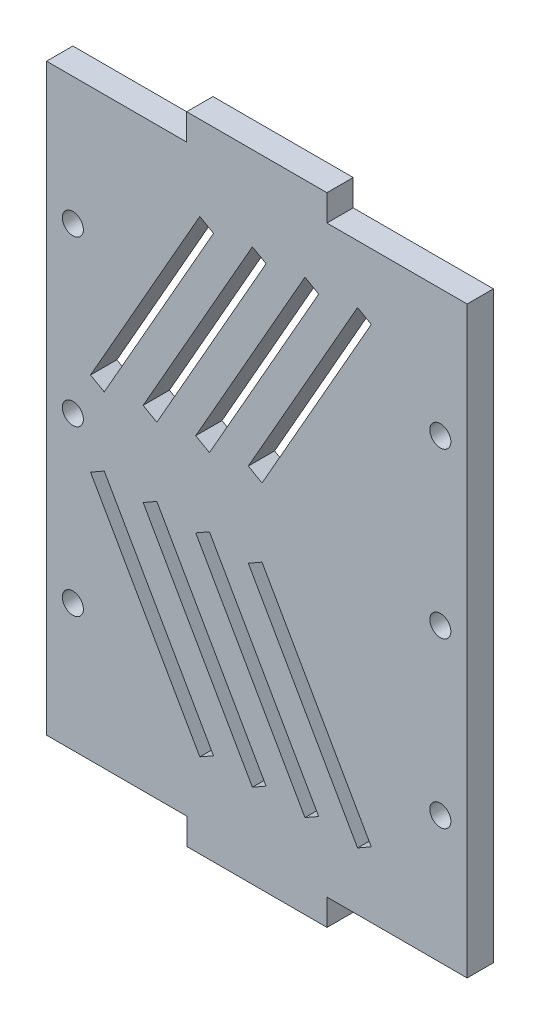
from build123d import *

# Parameters (mm, degrees)
CROQUIS1_W              = 79.981686337
CROQUIS1_H              = 111
SALIENTE_EXTRUIR1_DEPTH = 5
CROQUIS2_W              = 26.666666667
CROQUIS2_H              = 5
SALIENTE_EXTRUIR2_DEPTH = 5
CROQUIS3_W              = 26.666666666
CROQUIS3_H              = 5
SALIENTE_EXTRUIR3_DEPTH = 5
CROQUIS4_R              = 2
CORTAR_EXTRUIR1_DEPTH   = 10


with BuildPart() as part:
    # Croquis1 → Saliente-Extruir1 (new body)
    with BuildSketch(Plane.XY):
        with Locations((40.009156832, 55.428810295)):
            Rectangle(CROQUIS1_W, CROQUIS1_H)
        Polygon((40.989314194, 48.912995634), (38.382171337, 47.428810295), (59.160766092, 10.928810295), (61.767908949, 12.412995634), align=None, mode=Mode.SUBTRACT)
        Polygon((49.160766092, 10.928810295), (51.767908949, 12.412995634), (30.989314194, 48.912995634), (28.382171337, 47.428810295), align=None, mode=Mode.SUBTRACT)
        Polygon((20.989314194, 48.912995634), (18.382171337, 47.428810295), (39.160766092, 10.928810295), (41.767908949, 12.412995634), align=None, mode=Mode.SUBTRACT)
        Polygon((29.160766092, 10.928810295), (31.767908949, 12.412995634), (10.989314194, 48.912995634), (8.382171337, 47.428810295), align=None, mode=Mode.SUBTRACT)
        Polygon((38.382171337, 63.428810295), (40.989314194, 61.944624955), (61.767908949, 98.444624955), (59.160766092, 99.928810295), align=None, mode=Mode.SUBTRACT)
        Polygon((51.767908949, 98.444624955), (49.160766092, 99.928810295), (28.382171337, 63.428810295), (30.989314194, 61.944624955), align=None, mode=Mode.SUBTRACT)
        Polygon((18.382171337, 63.428810295), (20.989314194, 61.944624955), (41.767908949, 98.444624955), (39.160766092, 99.928810295), align=None, mode=Mode.SUBTRACT)
        Polygon((31.767908949, 98.444624955), (29.160766092, 99.928810295), (8.382171337, 63.428810295), (10.989314194, 61.944624955), align=None, mode=Mode.SUBTRACT)
    extrude(amount=SALIENTE_EXTRUIR1_DEPTH)

    # Croquis2 → Saliente-Extruir2 (add)
    with BuildSketch(Plane.XZ.offset(0.071189705)):
        with Locations((40.018313663, 2.5)):
            Rectangle(CROQUIS2_W, CROQUIS2_H)
    extrude(amount=SALIENTE_EXTRUIR2_DEPTH)

    # Croquis3 → Saliente-Extruir3 (add)
    with BuildSketch(Plane(origin=(0, 110.928810295, 0), x_dir=(1, 0, 0), z_dir=(0, 1, 0))):
        with Locations((40, -2.5)):
            Rectangle(CROQUIS3_W, CROQUIS3_H)
    extrude(amount=SALIENTE_EXTRUIR3_DEPTH)

    # Croquis4 → Cortar-Extruir1 (cut)
    with BuildSketch(Plane.XY.offset(5)):
        with Locations((74.9, 55.428810295)):
            Circle(CROQUIS4_R)
        with Locations((74.9, 86.678810295)):
            Circle(CROQUIS4_R)
        with Locations((74.9, 24.178810295)):
            Circle(CROQUIS4_R)
        with Locations((5.018313663, 55.428810295)):
            Circle(CROQUIS4_R)
        with Locations((5.018313663, 86.678810295)):
            Circle(CROQUIS4_R)
        with Locations((5.018313663, 24.178810295)):
            Circle(CROQUIS4_R)
    extrude(amount=-CORTAR_EXTRUIR1_DEPTH, mode=Mode.SUBTRACT)


solid = part.part
